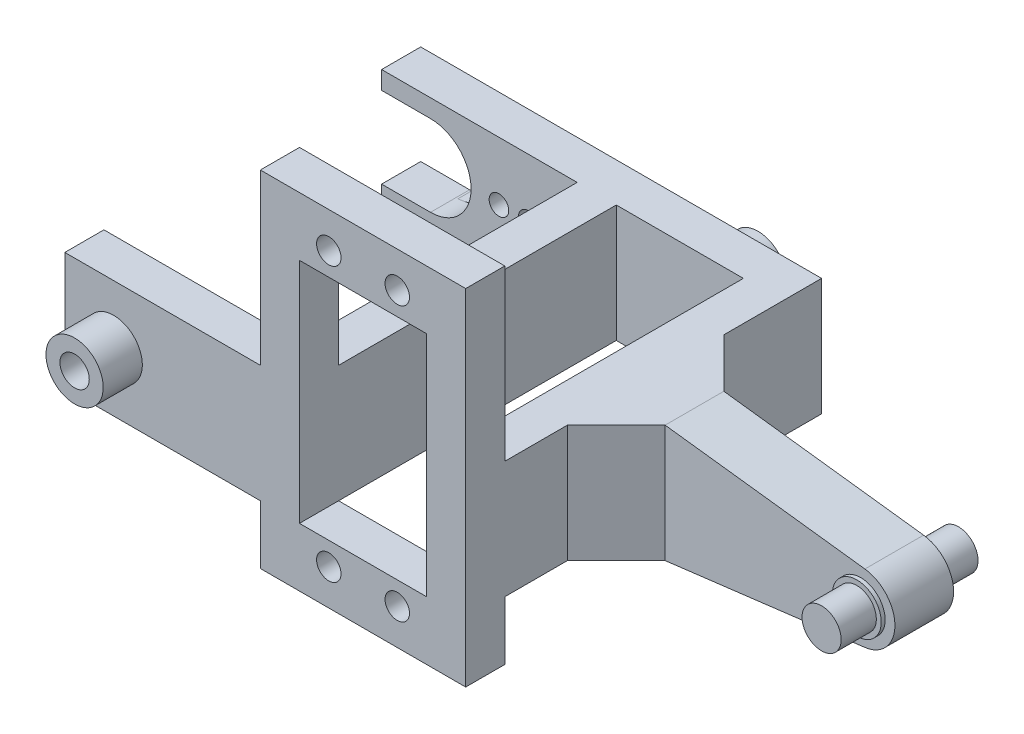
from build123d import *

# Parameters (mm, degrees)
EXTRUDE_1_DEPTH     = 12
SKETCH_2_W          = 21
SKETCH_2_H          = 35.3
SKETCH_2_R          = 1.25
SKETCH_2_W_2        = 13
SKETCH_2_H_2        = 23.3
EXTRUDE_2_DEPTH     = 4
EXTRUDE_START       = -18
EXTRUDE_3_DEPTH     = 3
CHAMFER_1_SIZE      = 5
EXTRUDE_START_2     = -3
SKETCH_4_R          = 2
EXTRUDE_4_DEPTH     = 7
CUT_EXTRUDE_1_DEPTH = 12
SKETCH_6_R          = 1
CUT_EXTRUDE_2_DEPTH = 1.4
SKETCH_6_3_R        = 1
CUT_EXTRUDE_3_DEPTH = 4
SKETCH_7_R          = 2.925
EXTRUDE_5_DEPTH     = 4
SKETCH_8_R          = 1.5
CUT_EXTRUDE_4_DEPTH = 5
SKETCH_9_R          = 2.925
EXTRUDE_6_DEPTH     = 4
SKETCH_10_R         = 1.5
CUT_EXTRUDE_5_DEPTH = 5
SKETCH_11_R         = 2.5
EXTRUDE_7_DEPTH     = 0.4
EXTRUDE_START_3     = 0.4
SKETCH_12_R         = 2.5
EXTRUDE_8_DEPTH     = 0.4


with BuildPart() as part:
    # 草图1 → 凸台-拉伸1 (new body)
    with BuildSketch(Plane(origin=(0, 0, 0), x_dir=(1, 0, 0), z_dir=(0, 1, 0))):
        Polygon((0, 0), (20, 0), (20, 28.4), (0, 28.4), (0, 32.4), (24, 32.4), (41, 32.4), (41, -4), (37, -4), (37, 28.4), (24, 28.4), (24, -4), (0, -4), align=None)
    extrude(amount=EXTRUDE_1_DEPTH)

    # 草图2 → 凸台-拉伸2 (add)
    with BuildSketch(Plane.XY.offset(4)):
        with Locations((30.5, 11.65)):
            Rectangle(SKETCH_2_W, SKETCH_2_H)
        with Locations((27, 25.65)):
            Circle(SKETCH_2_R, mode=Mode.SUBTRACT)
        with Locations((27, -2.35)):
            Circle(SKETCH_2_R, mode=Mode.SUBTRACT)
        with Locations((34, -2.35)):
            Circle(SKETCH_2_R, mode=Mode.SUBTRACT)
        with Locations((34, 25.65)):
            Circle(SKETCH_2_R, mode=Mode.SUBTRACT)
        with Locations((30.5, 11.65)):
            Rectangle(SKETCH_2_W_2, SKETCH_2_H_2, mode=Mode.SUBTRACT)
    extrude(amount=-EXTRUDE_2_DEPTH)

    # 草图3 → 凸台-拉伸3 (add, symmetric)
    with BuildSketch(Plane(origin=(0, 0, -32.4), x_dir=(-1, 0, 0), z_dir=(0, 0, -1)).offset(EXTRUDE_START)):
        with BuildLine():
            Line((-41, 12), (-46, 12))
            Line((-46, 12), (-66.429561848, 9.473539494))
            ThreePointArc((-66.429561848, 9.473539494), (-69.5, 6), (-66.429561848, 2.526460506))
            Line((-66.429561848, 2.526460506), (-46, 0))
            Line((-46, 0), (-41, 0))
            Line((-41, 0), (-41, 12))
        make_face()
    extrude(amount=EXTRUDE_3_DEPTH, both=True)

    # 倒角1
    chamfer_1_edges = [part.edges().sort_by_distance(p)[0] for p in [
        (41, 6, -17.4),
        (41, 6, -11.4),
    ]]
    chamfer(chamfer_1_edges, length=CHAMFER_1_SIZE)

    # 草图4 → 凸台-拉伸4 (add, symmetric)
    with BuildSketch(Plane(origin=(0, 0, -17.4), x_dir=(-1, 0, 0), z_dir=(0, 0, -1)).offset(EXTRUDE_START_2)):
        with Locations((-66, 6)):
            Circle(SKETCH_4_R)
    extrude(amount=EXTRUDE_4_DEPTH, both=True)

    # 草图5 → 切除-拉伸1 (cut)
    with BuildSketch(Plane(origin=(0, 0, -32.4), x_dir=(-1, 0, 0), z_dir=(0, 0, -1))):
        with BuildLine():
            Line((0, 1.85), (0, 10.15))
            Line((0, 10.15), (-5, 10.15))
            ThreePointArc((-5, 10.15), (-9.15, 6), (-5, 1.85))
            Line((-5, 1.85), (0, 1.85))
        make_face()
    extrude(amount=-CUT_EXTRUDE_1_DEPTH, mode=Mode.SUBTRACT)

    # 草图6 → 切除-拉伸2 (cut)
    with BuildSketch(Plane(origin=(0, 0, -32.4), x_dir=(-1, 0, 0), z_dir=(0, 0, -1))):
        with BuildLine():
            Line((-5.2075, 10.144809254), (-18.175, 9.495622262))
            ThreePointArc((-18.175, 9.495622262), (-21.5, 6), (-18.175, 2.504377738))
            Line((-18.175, 2.504377738), (-5.2075, 1.855190746))
            ThreePointArc((-5.2075, 1.855190746), (-9.15, 6), (-5.2075, 10.144809254))
        make_face()
        with Locations((-15, 6)):
            Circle(SKETCH_6_R, mode=Mode.SUBTRACT)
        with Locations((-12, 6)):
            Circle(SKETCH_6_R, mode=Mode.SUBTRACT)
        with Locations((-18, 6)):
            Circle(SKETCH_6_R, mode=Mode.SUBTRACT)
    extrude(amount=-CUT_EXTRUDE_2_DEPTH, mode=Mode.SUBTRACT)

    # 草图6<3> → 切除-拉伸3 (cut)
    with BuildSketch(Plane(origin=(0, 0, -32.4), x_dir=(-1, 0, 0), z_dir=(0, 0, -1))):
        with Locations((-15, 6)):
            Circle(SKETCH_6_3_R)
        with Locations((-12, 6)):
            Circle(SKETCH_6_3_R)
        with Locations((-18, 6)):
            Circle(SKETCH_6_3_R)
    extrude(amount=-CUT_EXTRUDE_3_DEPTH, mode=Mode.SUBTRACT)

    # 草图7 → 凸台-拉伸5 (add)
    with BuildSketch(Plane.XY.offset(4)):
        with Locations((5, 6)):
            Circle(SKETCH_7_R)
    extrude(amount=EXTRUDE_5_DEPTH)

    # 草图8 → 切除-拉伸4 (cut)
    with BuildSketch(Plane.XY.offset(8)):
        with Locations((5, 6)):
            Circle(SKETCH_8_R)
    extrude(amount=-CUT_EXTRUDE_4_DEPTH, mode=Mode.SUBTRACT)

    # 草图9 → 凸台-拉伸6 (add)
    with BuildSketch(Plane(origin=(0, 0, -32.4), x_dir=(-1, 0, 0), z_dir=(0, 0, -1))):
        with Locations((-30.5, 6)):
            Circle(SKETCH_9_R)
    extrude(amount=EXTRUDE_6_DEPTH)

    # 草图10 → 切除-拉伸5 (cut)
    with BuildSketch(Plane(origin=(0, 0, -36.4), x_dir=(-1, 0, 0), z_dir=(0, 0, -1))):
        with Locations((-30.5, 6)):
            Circle(SKETCH_10_R)
    extrude(amount=-CUT_EXTRUDE_5_DEPTH, mode=Mode.SUBTRACT)

    # 草图11 → 凸台-拉伸7 (add)
    with BuildSketch(Plane(origin=(0, 0, -17.4), x_dir=(-1, 0, 0), z_dir=(0, 0, -1))):
        with Locations((-66, 6)):
            Circle(SKETCH_11_R)
    extrude(amount=EXTRUDE_7_DEPTH)

    # 草图12 → 凸台-拉伸8 (add)
    with BuildSketch(Plane.XY.offset(-11.4).offset(EXTRUDE_START_3)):
        with Locations((66, 6)):
            Circle(SKETCH_12_R)
    extrude(amount=-EXTRUDE_8_DEPTH)


solid = part.part
